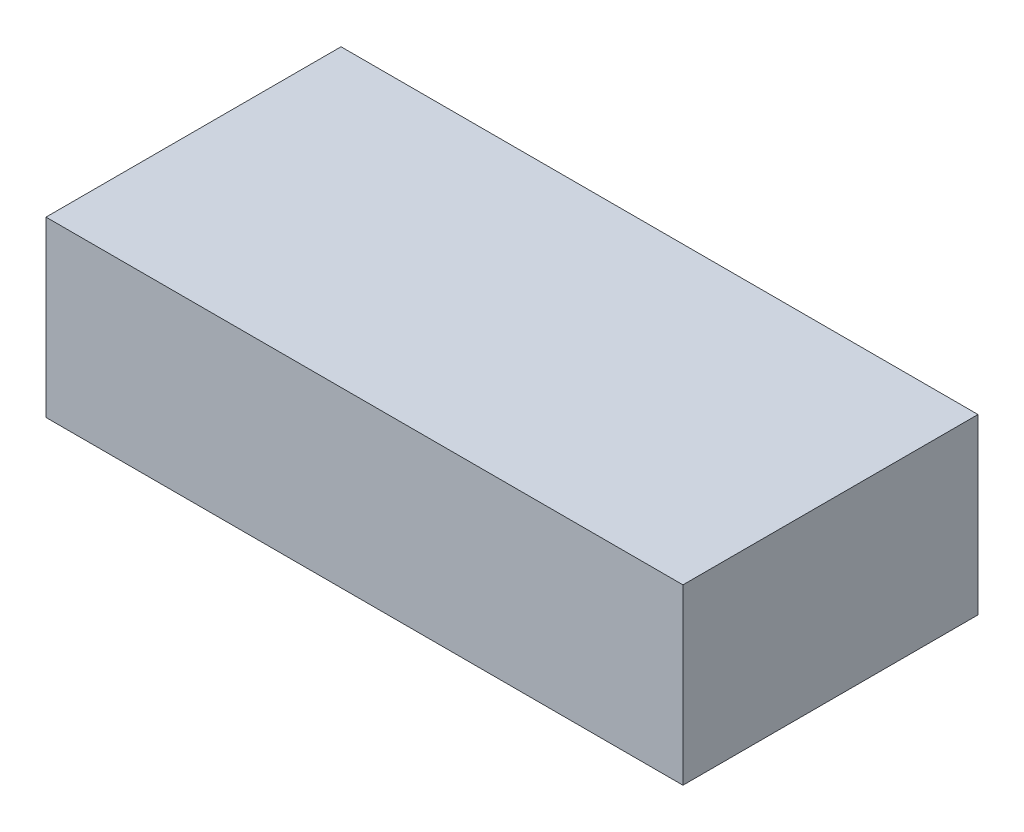
from build123d import *

# Parameters (mm, degrees)
SKETCH1_W           = 36.7
SKETCH1_H           = 17
BOSS_EXTRUDE1_DEPTH = 10


with BuildPart() as part:
    # Sketch1 → Boss-Extrude1 (new body)
    with BuildSketch(Plane(origin=(0, 0, 0), x_dir=(1, 0, 0), z_dir=(0, 1, 0))):
        with Locations((26.043572967, 19.030643411)):
            Rectangle(SKETCH1_W, SKETCH1_H)
    extrude(amount=BOSS_EXTRUDE1_DEPTH)


solid = part.part
